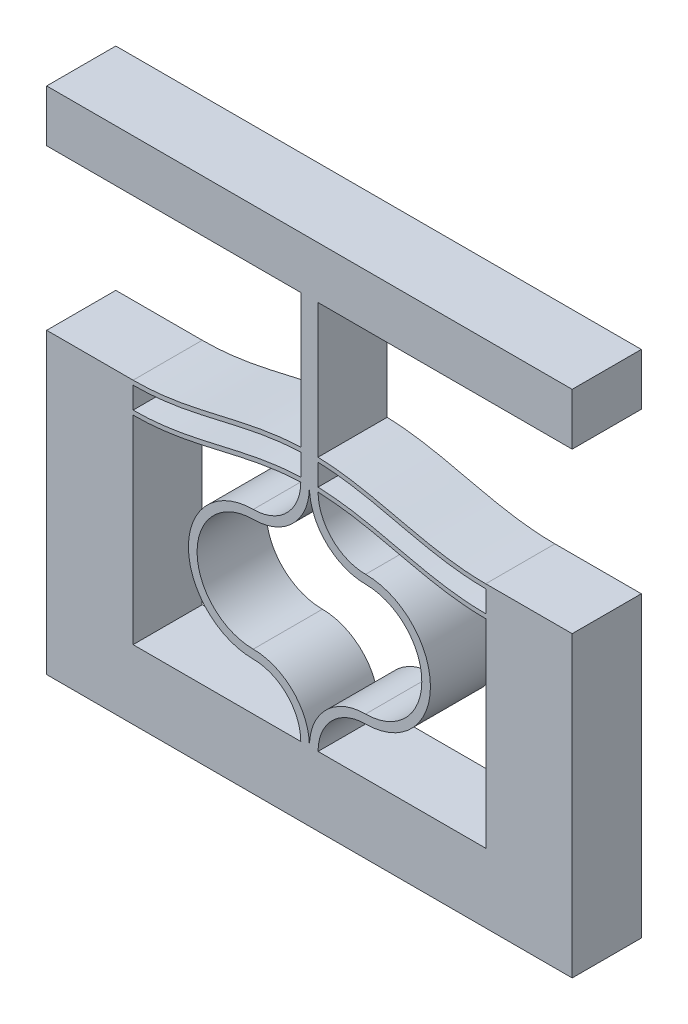
from build123d import *

# Parameters (mm, degrees)
BOSS_EXTRUDE1_DEPTH = 4
SKETCH4_W           = 1.000028655
SKETCH4_H           = 4
BOSS_EXTRUDE2_DEPTH = 1.5
MOVE_FACE1_BY       = 5
SKETCH8_W           = 30.40000001
SKETCH8_H           = 3
BOSS_EXTRUDE4_DEPTH = 4


with BuildPart() as part:
    # Sketch1 → Boss-Extrude1 (new body)
    with BuildSketch(Plane.XY):
        with BuildLine():
            add(Edge.make_bspline(
                [(10.700014224, 14.741123012), (10.769414318, 14.738663695), (11.03310814, 14.727603281), (11.490614063, 14.697170592), (12.262749669, 14.614202549), (13.344934017, 14.437909286), (14.416347819, 14.207015891), (15.483183095, 13.956131655), (16.319838847, 13.766249034), (16.857815383, 13.652304096), (17.362886901, 13.553302991), (17.776414428, 13.479790745), (18.203500731, 13.412396588), (18.656257538, 13.353987061), (18.987768381, 13.3179099), (19.289919617, 13.293036934), (19.513652899, 13.276508776), (19.742348402, 13.265861771), (19.917436469, 13.255829602), (20.20131205, 13.251344917), (20.318835942, 13.249999512), (20.4, 13.249999512)],
                knots=[0.520196639, 0.520196639, 0.520196639, 0.520196639, 0.520196639, 0.53141408, 0.562828159, 0.594242235, 0.645597029, 0.708425214, 0.739839305, 0.771253396, 0.784217346, 0.797181296, 0.823109196, 0.838816246, 0.854523296, 0.870230336, 0.878083855, 0.885937375, 0.893790894, 0.901644413, 0.917351451, 0.917351451, 0.917351451, 0.917351451, 0.917351451], degree=4))
            Line((10.700014224, 14.741123012), (10.700014224, 15.991123012))
            Line((10.700014224, 15.991123012), (9.699985569, 15.991123012))
            Line((9.699985569, 15.991123012), (9.699985569, 14.741123012))
            add(Edge.make_bspline(
                [(0, 13.249999512), (0.081164058, 13.249999512), (0.199729304, 13.251344907), (0.473779629, 13.255829663), (0.709191365, 13.267868104), (1.033438356, 13.285149543), (1.35158977, 13.312755641), (1.750162777, 13.353987577), (2.192328474, 13.412395709), (2.7057608, 13.49221948), (3.305792882, 13.602949191), (4.002230953, 13.748490017), (4.916593693, 13.956132269), (5.983810028, 14.207015465), (7.054976456, 14.437909533), (8.137289789, 14.614202431), (8.909375138, 14.697170645), (9.366886361, 14.727603295), (9.630584373, 14.738663696), (9.699985569, 14.741123012)],
                knots=[0.082648549, 0.082648549, 0.082648549, 0.082648549, 0.082648549, 0.098355587, 0.106209106, 0.114062625, 0.129769664, 0.145476704, 0.161183754, 0.176890804, 0.202818704, 0.228746604, 0.260160695, 0.291574786, 0.354402971, 0.405757765, 0.437171841, 0.46858592, 0.479803371, 0.479803371, 0.479803371, 0.479803371, 0.479803371], degree=4))
            Line((0, 13.249999512), (-5.000000005, 13.249999512))
            Line((-5.000000005, 13.249999512), (-5.000000005, -4))
            Line((-5.000000005, -4), (25.400000005, -4))
            Line((25.400000005, -4), (25.400000005, 13.249999512))
            Line((25.400000005, 13.249999512), (20.4, 13.249999512))
        make_face()
        with BuildLine():
            Line((9.699985569, 14.491123012), (9.699985569, 13.241123012))
            add(Edge.make_bspline(
                [(0, 11.749999512), (0.081164058, 11.749999512), (0.199729304, 11.751344907), (0.473779629, 11.755829663), (0.709191365, 11.767868104), (1.033438356, 11.785149543), (1.35158977, 11.812755641), (1.750162777, 11.853987577), (2.192328474, 11.912395709), (2.7057608, 11.99221948), (3.305792882, 12.102949191), (4.002230953, 12.248490017), (4.916593693, 12.456132269), (5.983810028, 12.707015465), (7.054976456, 12.937909533), (8.137289789, 13.114202431), (8.909375138, 13.197170645), (9.366886361, 13.227603295), (9.630584373, 13.238663696), (9.699985569, 13.241123012)],
                knots=[0.082648549, 0.082648549, 0.082648549, 0.082648549, 0.082648549, 0.098355587, 0.106209106, 0.114062625, 0.129769664, 0.145476704, 0.161183754, 0.176890804, 0.202818704, 0.228746604, 0.260160695, 0.291574786, 0.354402971, 0.405757765, 0.437171841, 0.46858592, 0.479803371, 0.479803371, 0.479803371, 0.479803371, 0.479803371], degree=4))
            Line((0, 11.749999512), (0, 12.999999512))
            add(Edge.make_bspline(
                [(0, 12.999999512), (0.081164058, 12.999999512), (0.199729304, 13.001344907), (0.473779629, 13.005829663), (0.709191365, 13.017868104), (1.033438356, 13.035149543), (1.35158977, 13.062755641), (1.750162777, 13.103987577), (2.192328474, 13.162395709), (2.7057608, 13.24221948), (3.305792882, 13.352949191), (4.002230953, 13.498490017), (4.916593693, 13.706132269), (5.983810028, 13.957015465), (7.054976456, 14.187909533), (8.137289789, 14.364202431), (8.909375138, 14.447170645), (9.366886361, 14.477603295), (9.630584373, 14.488663696), (9.699985569, 14.491123012)],
                knots=[0.082648549, 0.082648549, 0.082648549, 0.082648549, 0.082648549, 0.098355587, 0.106209106, 0.114062625, 0.129769664, 0.145476704, 0.161183754, 0.176890804, 0.202818704, 0.228746604, 0.260160695, 0.291574786, 0.354402971, 0.405757765, 0.437171841, 0.46858592, 0.479803371, 0.479803371, 0.479803371, 0.479803371, 0.479803371], degree=4))
        make_face(mode=Mode.SUBTRACT)
        with BuildLine():
            Line((10.700014224, 13.241123012), (10.700014224, 14.491123012))
            add(Edge.make_bspline(
                [(10.700014224, 14.491123012), (10.769414318, 14.488663695), (11.03310814, 14.477603281), (11.490614063, 14.447170592), (12.262749669, 14.364202549), (13.344934017, 14.187909286), (14.416347819, 13.957015891), (15.483183095, 13.706131655), (16.319838847, 13.516249034), (16.857815383, 13.402304096), (17.362886901, 13.303302991), (17.776414428, 13.229790745), (18.203500731, 13.162396588), (18.656257538, 13.103987061), (18.987768381, 13.0679099), (19.289919617, 13.043036934), (19.513652899, 13.026508776), (19.742348402, 13.015861771), (19.917436469, 13.005829602), (20.20131205, 13.001344917), (20.318835942, 12.999999512), (20.4, 12.999999512)],
                knots=[0.520196639, 0.520196639, 0.520196639, 0.520196639, 0.520196639, 0.53141408, 0.562828159, 0.594242235, 0.645597029, 0.708425214, 0.739839305, 0.771253396, 0.784217346, 0.797181296, 0.823109196, 0.838816246, 0.854523296, 0.870230336, 0.878083855, 0.885937375, 0.893790894, 0.901644413, 0.917351451, 0.917351451, 0.917351451, 0.917351451, 0.917351451], degree=4))
            Line((20.4, 12.999999512), (20.4, 11.749999512))
            add(Edge.make_bspline(
                [(10.700014224, 13.241123012), (10.769414318, 13.238663695), (11.03310814, 13.227603281), (11.490614063, 13.197170592), (12.262749669, 13.114202549), (13.344934017, 12.937909286), (14.416347819, 12.707015891), (15.483183095, 12.456131655), (16.319838847, 12.266249034), (16.857815383, 12.152304096), (17.362886901, 12.053302991), (17.776414428, 11.979790745), (18.203500731, 11.912396588), (18.656257538, 11.853987061), (18.987768381, 11.8179099), (19.289919617, 11.793036934), (19.513652899, 11.776508776), (19.742348402, 11.765861771), (19.917436469, 11.755829602), (20.20131205, 11.751344917), (20.318835942, 11.749999512), (20.4, 11.749999512)],
                knots=[0.520196639, 0.520196639, 0.520196639, 0.520196639, 0.520196639, 0.53141408, 0.562828159, 0.594242235, 0.645597029, 0.708425214, 0.739839305, 0.771253396, 0.784217346, 0.797181296, 0.823109196, 0.838816246, 0.854523296, 0.870230336, 0.878083855, 0.885937375, 0.893790894, 0.901644413, 0.917351451, 0.917351451, 0.917351451, 0.917351451, 0.917351451], degree=4))
        make_face(mode=Mode.SUBTRACT)
        with BuildLine():
            Line((0, 0), (0, 11.499999512))
            add(Edge.make_bspline(
                [(0, 11.499999512), (0.081164058, 11.499999512), (0.199729304, 11.501344907), (0.473779629, 11.505829663), (0.709191365, 11.517868104), (1.033438356, 11.535149543), (1.35158977, 11.562755641), (1.750162777, 11.603987577), (2.192328474, 11.662395709), (2.7057608, 11.74221948), (3.305792882, 11.852949191), (4.002230953, 11.998490017), (4.916593693, 12.206132269), (5.983810028, 12.457015465), (7.054976456, 12.687909533), (8.137289789, 12.864202431), (8.909375138, 12.947170645), (9.366886361, 12.977603295), (9.630584373, 12.988663696), (9.699985569, 12.991123012)],
                knots=[0.082648549, 0.082648549, 0.082648549, 0.082648549, 0.082648549, 0.098355587, 0.106209106, 0.114062625, 0.129769664, 0.145476704, 0.161183754, 0.176890804, 0.202818704, 0.228746604, 0.260160695, 0.291574786, 0.354402971, 0.405757765, 0.437171841, 0.46858592, 0.479803371, 0.479803371, 0.479803371, 0.479803371, 0.479803371], degree=4))
            ThreePointArc((9.699985569, 12.991123012), (8.891402518, 11.052320391), (6.949999896, 10.25))
            ThreePointArc((6.949999896, 10.25), (3.199999896, 6.5), (6.949999896, 2.75))
            ThreePointArc((6.949999896, 2.75), (8.894543545, 1.944543648), (9.699999896, 0))
            Line((9.699999896, 0), (0, 0))
        make_face(mode=Mode.SUBTRACT)
        with BuildLine():
            ThreePointArc((6.949999896, 9.75), (9.248096935, 10.701902961), (10.199999896, 13))
            ThreePointArc((10.199999896, 13), (11.151902857, 10.701902961), (13.449999896, 9.75))
            ThreePointArc((13.449999896, 9.75), (16.699999896, 6.5), (13.449999896, 3.25))
            ThreePointArc((13.449999896, 3.25), (11.151902857, 2.298097039), (10.199999896, 0))
            ThreePointArc((10.199999896, 0), (9.248096935, 2.298097039), (6.949999896, 3.25))
            ThreePointArc((6.949999896, 3.25), (3.699999896, 6.5), (6.949999896, 9.75))
        make_face(mode=Mode.SUBTRACT)
        with BuildLine():
            ThreePointArc((13.449999896, 10.25), (11.508597274, 11.052320391), (10.700014224, 12.991123012))
            add(Edge.make_bspline(
                [(10.700014224, 12.991123012), (10.769414318, 12.988663695), (11.03310814, 12.977603281), (11.490614063, 12.947170592), (12.262749669, 12.864202549), (13.344934017, 12.687909286), (14.416347819, 12.457015891), (15.483183095, 12.206131655), (16.319838847, 12.016249034), (16.857815383, 11.902304096), (17.362886901, 11.803302991), (17.776414428, 11.729790745), (18.203500731, 11.662396588), (18.656257538, 11.603987061), (18.987768381, 11.5679099), (19.289919617, 11.543036934), (19.513652899, 11.526508776), (19.742348402, 11.515861771), (19.917436469, 11.505829602), (20.20131205, 11.501344917), (20.318835942, 11.499999512), (20.4, 11.499999512)],
                knots=[0.520196639, 0.520196639, 0.520196639, 0.520196639, 0.520196639, 0.53141408, 0.562828159, 0.594242235, 0.645597029, 0.708425214, 0.739839305, 0.771253396, 0.784217346, 0.797181296, 0.823109196, 0.838816246, 0.854523296, 0.870230336, 0.878083855, 0.885937375, 0.893790894, 0.901644413, 0.917351451, 0.917351451, 0.917351451, 0.917351451, 0.917351451], degree=4))
            Line((20.4, 11.499999512), (20.4, 0))
            Line((20.4, 0), (10.699999896, 0))
            ThreePointArc((10.699999896, 0), (11.505456248, 1.944543648), (13.449999896, 2.75))
            ThreePointArc((13.449999896, 2.75), (17.199999896, 6.5), (13.449999896, 10.25))
        make_face(mode=Mode.SUBTRACT)
    extrude(amount=BOSS_EXTRUDE1_DEPTH)

    # Sketch4 → Boss-Extrude2 (add)
    with BuildSketch(Plane(origin=(0, 15.991123012, 0), x_dir=(1, 0, 0), z_dir=(0, 1, 0))):
        with Locations((10.199999896, -2)):
            Rectangle(SKETCH4_W, SKETCH4_H)
    extrude(amount=BOSS_EXTRUDE2_DEPTH)

    # Move Face1: a face moved outward by 5.0
    extrude(part.faces().sort_by_distance((10.199999896, 17.491123012, 2))[0], amount=MOVE_FACE1_BY, dir=(0, 1, 0))

    # Sketch8 → Boss-Extrude4 (add)
    with BuildSketch(Plane.XY.offset(4)):
        with Locations((10.2, 23.991123012)):
            Rectangle(SKETCH8_W, SKETCH8_H)
    extrude(amount=-BOSS_EXTRUDE4_DEPTH)


solid = part.part
